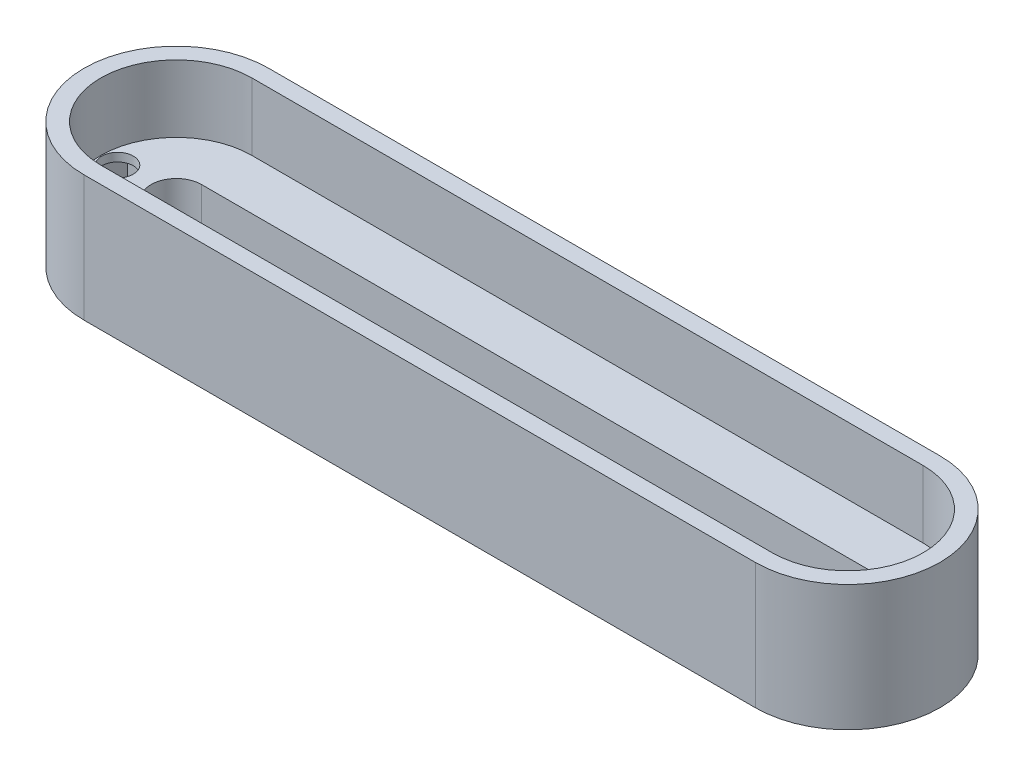
from build123d import *

# Parameters (mm, degrees)
SALIENTE_EXTRUIR1_DEPTH    = 12
CORTAR_EXTRUIR1_DEPTH      = 6
CROQUIS5_R                 = 1.875
CORTAR_EXTRUIR2_DEPTH      = 7
CORTAR_EXTRUIR2_DEPTH_BACK = 7
CROQUIS6_W                 = 80
CROQUIS6_H                 = 8
CROQUIS6_R                 = 1.875
SALIENTE_EXTRUIR4_DEPTH    = 3
CORTAR_EXTRUIR3_DEPTH      = 8


with BuildPart() as part:
    # Croquis1 → Saliente-Extruir1 (new body)
    with BuildSketch(Plane(origin=(0, 0, 0), x_dir=(1, 0, 0), z_dir=(0, 1, 0))):
        with BuildLine():
            Line((-40, 11), (40, 11))
            ThreePointArc((40, 11), (51, 0), (40, -11))
            Line((40, -11), (-40, -11))
            ThreePointArc((-40, -11), (-51, 0), (-40, 11))
        make_face()
        with BuildLine():
            Line((-40, 3), (40, 3))
            ThreePointArc((40, 3), (43, 0), (40, -3))
            Line((40, -3), (-40, -3))
            ThreePointArc((-40, -3), (-43, 0), (-40, 3))
        make_face(mode=Mode.SUBTRACT)
    extrude(amount=SALIENTE_EXTRUIR1_DEPTH)

    # Croquis2 → Cortar-Extruir1 (cut)
    with BuildSketch(Plane(origin=(0, 0, 0), x_dir=(1, 0, 0), z_dir=(0, 1, 0))):
        Polygon((45.4, -2.771281292), (43.8, 0), (45.4, 2.771281292), (48.6, 2.771281292), (50.2, 0), (48.6, -2.771281292), align=None)
        Polygon((-45.4, 2.771281292), (-48.6, 2.771281292), (-50.2, 0), (-48.6, -2.771281292), (-45.4, -2.771281292), (-43.8, 0), align=None)
    extrude(amount=CORTAR_EXTRUIR1_DEPTH, mode=Mode.SUBTRACT)

    # Croquis5 → Cortar-Extruir2 (cut, two sides)
    with BuildSketch(Plane.XZ.offset(-6)) as cortar_extruir2_sk:
        with Locations((-47, 0)):
            Circle(CROQUIS5_R)
        with Locations((47, 0)):
            Circle(CROQUIS5_R)
    extrude(amount=CORTAR_EXTRUIR2_DEPTH, mode=Mode.SUBTRACT)
    extrude(cortar_extruir2_sk.sketch, amount=-CORTAR_EXTRUIR2_DEPTH_BACK, mode=Mode.SUBTRACT)

    # Croquis6 → Saliente-Extruir4 (add)
    with BuildSketch(Plane(origin=(0, 12, 0), x_dir=(1, 0, 0), z_dir=(0, 1, 0))):
        with Locations((0, 7)):
            Rectangle(CROQUIS6_W, CROQUIS6_H)
        with Locations((0, -7)):
            Rectangle(CROQUIS6_W, CROQUIS6_H)
        with BuildLine():
            Line((-40, 3), (-40, 11))
            ThreePointArc((-40, 11), (-51, 0), (-40, -11))
            Line((-40, -11), (-40, -3))
            ThreePointArc((-40, -3), (-43, 0), (-40, 3))
        make_face()
        with Locations((-47, 0)):
            Circle(CROQUIS6_R, mode=Mode.SUBTRACT)
        with BuildLine():
            ThreePointArc((40, -11), (51, 0), (40, 11))
            Line((40, 11), (40, 3))
            ThreePointArc((40, 3), (43, 0), (40, -3))
            Line((40, -3), (40, -11))
        make_face()
        with Locations((47, 0)):
            Circle(CROQUIS6_R, mode=Mode.SUBTRACT)
    extrude(amount=SALIENTE_EXTRUIR4_DEPTH)

    # Croquis7 → Cortar-Extruir3 (cut)
    with BuildSketch(Plane(origin=(0, 15, 0), x_dir=(1, 0, 0), z_dir=(0, 1, 0))):
        with BuildLine():
            Line((-40, 9), (40, 9))
            ThreePointArc((40, 9), (49, 0), (40, -9))
            Line((40, -9), (-40, -9))
            ThreePointArc((-40, -9), (-49, 0), (-40, 9))
        make_face()
    extrude(amount=-CORTAR_EXTRUIR3_DEPTH, mode=Mode.SUBTRACT)


solid = part.part
